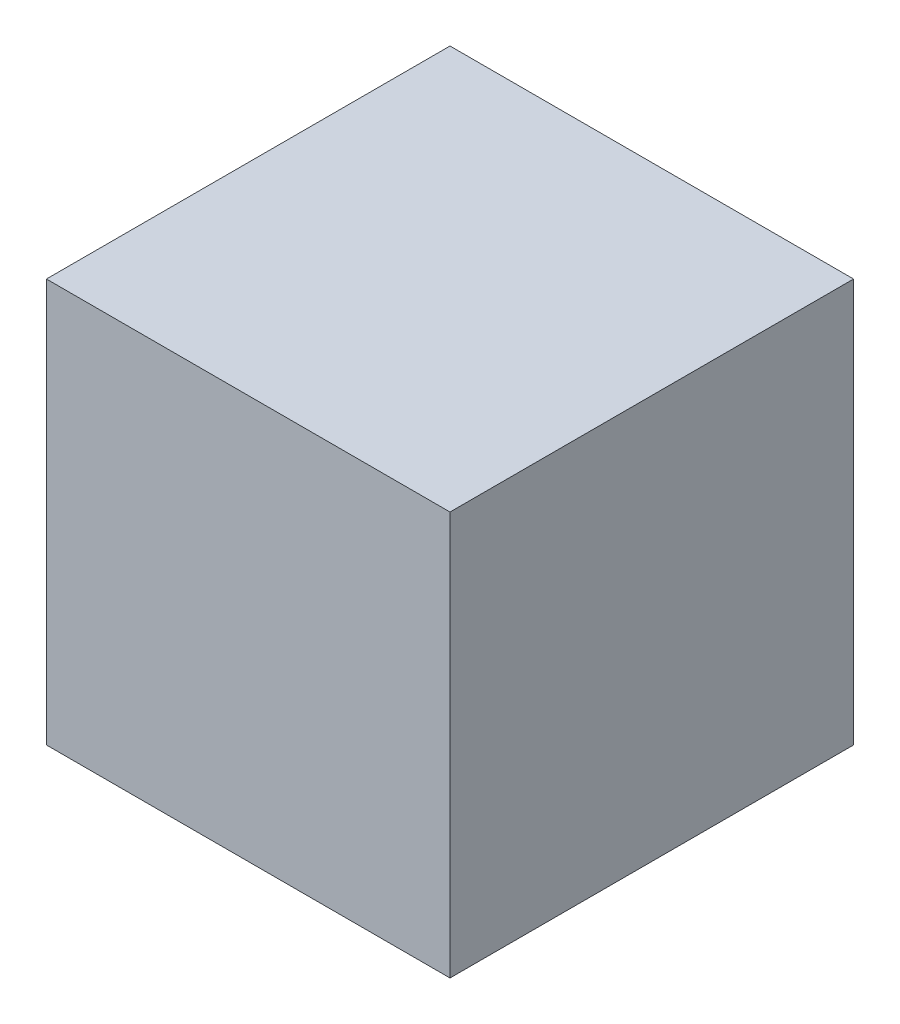
from build123d import *

# Parameters (mm, degrees)
SKETCH1_W           = 80
SKETCH1_H           = 80
BOSS_EXTRUDE1_DEPTH = 80


with BuildPart() as part:
    # Sketch1 → Boss-Extrude1 (new body)
    with BuildSketch(Plane(origin=(0, 0, 0), x_dir=(1, 0, 0), z_dir=(0, 1, 0))):
        Rectangle(SKETCH1_W, SKETCH1_H)
    extrude(amount=BOSS_EXTRUDE1_DEPTH)


solid = part.part
